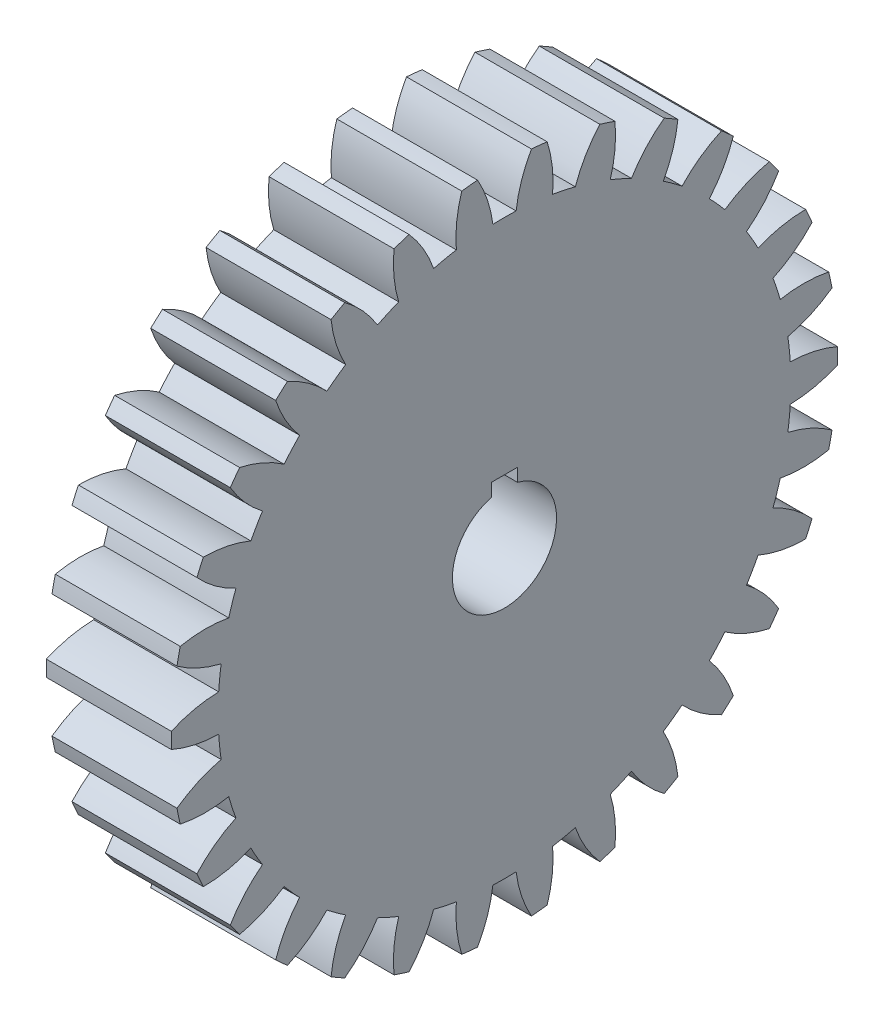
from build123d import *

# Parameters (mm, degrees)
BASPROSKE_W     = 304.8
BASPROSKE_H     = 812.8
TOOTHCUT_DEPTH  = 1190.197510929
TEETHCUTS_COUNT = 30
TEETHCUTS_ANGLE = 348
BORSKE_R        = 127
BORE_DEPTH      = 304.8000508
KEYSKE_W        = 63.5
KEYSKE_H        = 154.8384
KEYWAY_DEPTH    = 304.8000508


with BuildPart() as part:
    # BasProSke → Base-Revolve (revolve)
    with BuildSketch(Plane(origin=(0, 0, 0), x_dir=(1, 0, 0), z_dir=(0, 1, 0)), mode=Mode.PRIVATE) as base_revolve_sk:
        with Locations((152.4, 406.4)):
            Rectangle(BASPROSKE_W, BASPROSKE_H)
    revolve(base_revolve_sk.sketch.rotate(Axis((-10, 0, 0), (1, 0, 0)), 180), axis=Axis((-10, 0, 0), (1, 0, 0)))

    # TooCutSke → ToothCut (cut, through all)
    with BuildSketch(Plane(origin=(0, 0, 0), x_dir=(0, 0, -1), z_dir=(1, 0, 0))):
        with BuildLine():
            ThreePointArc((28.319737367, 697.924400123), (0, 698.49873), (-28.319737367, 697.924400123))
            ThreePointArc((-28.319737367, 697.924400123), (-41.533758507, 755.876600482), (-65.744032335, 810.162238751))
            ThreePointArc((-65.744032335, 810.162238751), (0, 812.8254), (65.744032335, 810.162238751))
            ThreePointArc((65.744032335, 810.162238751), (41.533758507, 755.876600482), (28.319737367, 697.924400123))
        make_face()
    toothcut = extrude(amount=TOOTHCUT_DEPTH, mode=Mode.SUBTRACT)

    # TeethCuts: ToothCut ×30 about axis
    teethcuts_axis = Axis((-10, 0, 0), (1, 0, 0))
    for i in range(1, TEETHCUTS_COUNT):
        add(toothcut.rotate(teethcuts_axis, i * TEETHCUTS_ANGLE / (TEETHCUTS_COUNT - 1)), mode=Mode.SUBTRACT)

    # BorSke → Bore (cut, symmetric)
    with BuildSketch(Plane(origin=(0, 0, 0), x_dir=(0, 0, -1), z_dir=(1, 0, 0))):
        with Locations(Location((0, 0, 0), (0, 0, 180))):
            Circle(BORSKE_R)
    extrude(amount=BORE_DEPTH, both=True, mode=Mode.SUBTRACT)

    # KeySke → Keyway (cut, symmetric)
    with BuildSketch(Plane(origin=(0, 0, 0), x_dir=(0, 0, -1), z_dir=(1, 0, 0))):
        with Locations((0, 77.4192)):
            Rectangle(KEYSKE_W, KEYSKE_H)
    extrude(amount=KEYWAY_DEPTH, both=True, mode=Mode.SUBTRACT)


solid = part.part
